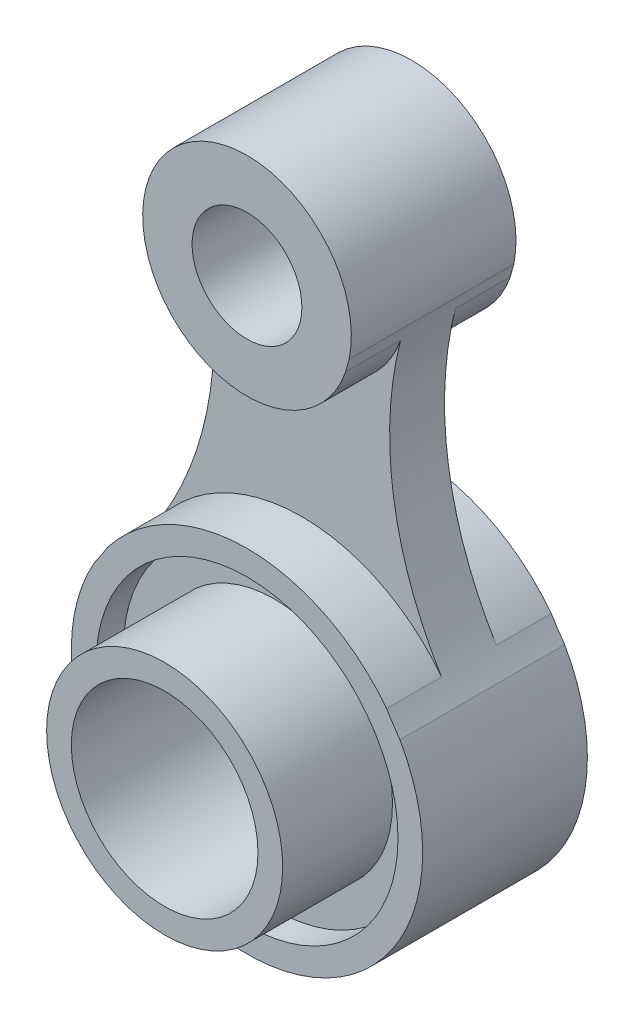
from build123d import *

# Parameters (mm, degrees)
BOSS_EXTRUDE6_DEPTH       = 10
BOSS_EXTRUDE10_DEPTH      = 20
BOSS_EXTRUDE10_DEPTH_BACK = 10
SKETCH1_11_R              = 27.5
BOSS_EXTRUDE11_DEPTH      = 20
BOSS_EXTRUDE11_DEPTH_BACK = 10
SKETCH1_12_R              = 10
BOSS_EXTRUDE12_DEPTH      = 15
BOSS_EXTRUDE12_DEPTH_BACK = 10
SKETCH1_13_R              = 27.5
SKETCH1_13_R_2            = 21.5
BOSS_EXTRUDE13_DEPTH      = 35
BOSS_EXTRUDE13_DEPTH_BACK = 10
SKETCH1_14_R              = 21.5
SKETCH1_14_R_2            = 17


with BuildPart() as part:
    # Sketch1 → Boss-Extrude6 (new body)
    with BuildSketch(Plane.XY):
        with BuildLine():
            ThreePointArc((-25.420986444, 19.436394938), (0, 32), (25.420986444, 19.436394938))
            ThreePointArc((25.420986444, 19.436394938), (16.698881669, 43.372332346), (17.965602149, 68.816381365))
            ThreePointArc((17.965602149, 68.816381365), (0, 56), (-17.965602149, 68.816381365))
            ThreePointArc((-17.965602149, 68.816381365), (-16.698881669, 43.372332346), (-25.420986444, 19.436394938))
        make_face()
    extrude(amount=BOSS_EXTRUDE6_DEPTH)

    # Sketch1_11 → Boss-Extrude10 (add, two sides: drawn at the far end of the back side and taken through both)
    with BuildSketch(Plane.XY.offset(-BOSS_EXTRUDE10_DEPTH_BACK)):
        with BuildLine():
            ThreePointArc((-27.861197674, 15.740192635), (-8.137618645, -30.948007412), (32, 0))
            ThreePointArc((32, 0), (30.948007412, 8.137618645), (27.861197674, 15.740192635))
            ThreePointArc((27.861197674, 15.740192635), (26.609230485, 17.567258961), (25.420986444, 19.436394938))
            ThreePointArc((25.420986444, 19.436394938), (0, 32), (-25.420986444, 19.436394938))
            ThreePointArc((-25.420986444, 19.436394938), (-26.609230485, 17.567258961), (-27.861197674, 15.740192635))
        make_face()
        Circle(SKETCH1_11_R, mode=Mode.SUBTRACT)
    extrude(amount=BOSS_EXTRUDE10_DEPTH + BOSS_EXTRUDE10_DEPTH_BACK)

    # Sketch1_12 → Boss-Extrude11 (add, two sides: drawn at the far end of the back side and taken through both)
    with BuildSketch(Plane.XY.offset(-BOSS_EXTRUDE11_DEPTH_BACK)):
        with BuildLine():
            ThreePointArc((-17.965602149, 68.816381365), (0, 56), (17.965602149, 68.816381365))
            ThreePointArc((17.965602149, 68.816381365), (18.273648583, 69.980415685), (18.603456766, 71.138472275))
            ThreePointArc((18.603456766, 71.138472275), (18.900604204, 73.059082504), (19, 75))
            ThreePointArc((19, 75), (-1.940917496, 93.900604204), (-18.603456766, 71.138472275))
            ThreePointArc((-18.603456766, 71.138472275), (-18.273648583, 69.980415685), (-17.965602149, 68.816381365))
        make_face()
        with Locations((0, 75)):
            Circle(SKETCH1_12_R, mode=Mode.SUBTRACT)
    extrude(amount=BOSS_EXTRUDE11_DEPTH + BOSS_EXTRUDE11_DEPTH_BACK)

    # Sketch1_13 → Boss-Extrude12 (add, two sides: drawn at the far end of the back side and taken through both)
    with BuildSketch(Plane.XY.offset(-BOSS_EXTRUDE12_DEPTH_BACK)):
        Circle(SKETCH1_13_R)
        Circle(SKETCH1_13_R_2, mode=Mode.SUBTRACT)
    extrude(amount=BOSS_EXTRUDE12_DEPTH + BOSS_EXTRUDE12_DEPTH_BACK)

    # Sketch1_14 → Boss-Extrude13 (add, two sides: drawn at the far end of the back side and taken through both)
    with BuildSketch(Plane.XY.offset(-BOSS_EXTRUDE13_DEPTH_BACK)):
        Circle(SKETCH1_14_R)
        Circle(SKETCH1_14_R_2, mode=Mode.SUBTRACT)
    extrude(amount=BOSS_EXTRUDE13_DEPTH + BOSS_EXTRUDE13_DEPTH_BACK)


solid = part.part
